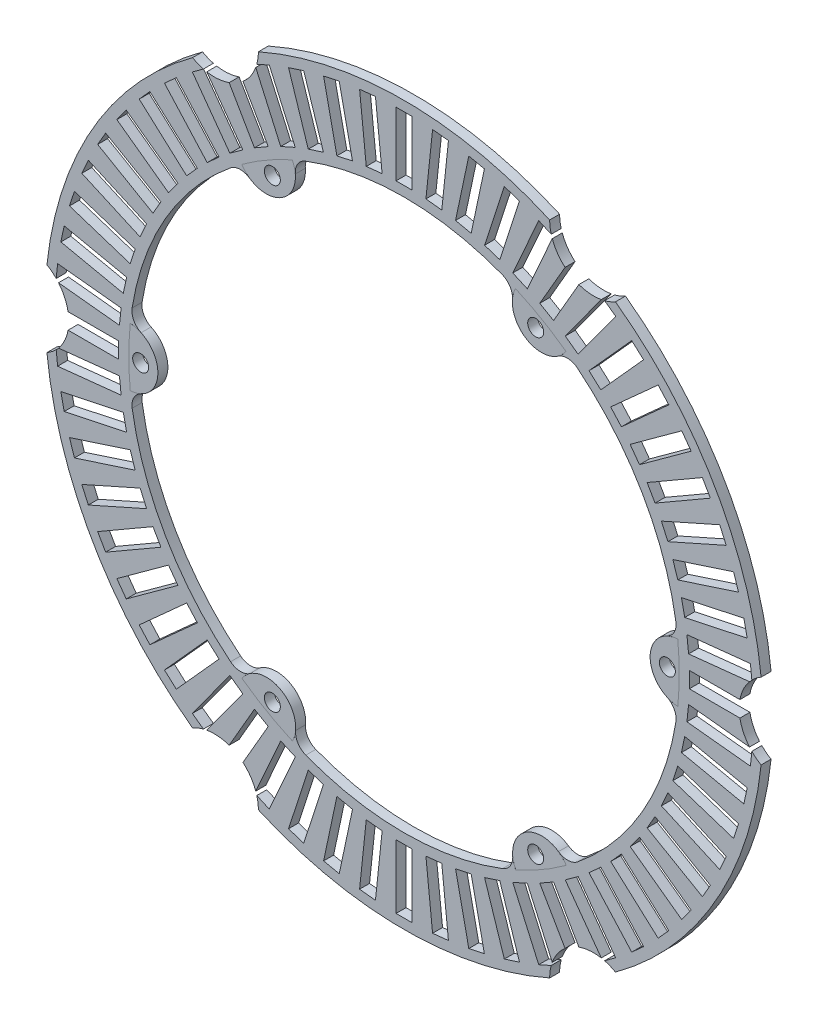
from build123d import *

# Parameters (mm, degrees)
SKETCH1_R                 = 57.15
SKETCH1_R_2               = 43.815
BOSS_EXTRUDE1_DEPTH       = 1.5875
SKETCH4_W                 = 2.54
SKETCH4_H                 = 10.16
CUT_EXTRUDE3_DEPTH        = 5.08
CIRPATTERN2_COUNT         = 60
SKETCH7_R                 = 6.985
CUT_EXTRUDE5_DEPTH        = 2.54
CIRPATTERN4_COUNT         = 6
BOSS_EXTRUDE2_START       = -1.5875
BOSS_EXTRUDE2_DEPTH       = 1.587512
FILLET1_R                 = 2.54
CUT_EXTRUDE6_START        = -2.5875121
SKETCH9_R                 = 1.27
CUT_EXTRUDE6_DEPTH        = 3.5875122
CIRPATTERN12_COUNT        = 6
FILLET1_OF_CIRPATTERN12_R = 2.54


with BuildPart() as part:
    # Sketch1 → Boss-Extrude1 (new body)
    with BuildSketch(Plane.XY):
        Circle(SKETCH1_R)
        Circle(SKETCH1_R_2, mode=Mode.SUBTRACT)
    extrude(amount=BOSS_EXTRUDE1_DEPTH)

    # Sketch4 → Cut-Extrude3 (cut)
    with BuildSketch(Plane.XY.offset(1.5875)):
        with Locations((0, 50.4825)):
            Rectangle(SKETCH4_W, SKETCH4_H)
    cut_extrude3 = extrude(amount=-CUT_EXTRUDE3_DEPTH, mode=Mode.SUBTRACT)

    # CirPattern2: Cut-Extrude3 ×60 about axis
    cirpattern2_axis = Axis((0, 0, 0), (0, 0, 1))
    for i in range(1, CIRPATTERN2_COUNT):
        add(cut_extrude3.rotate(cirpattern2_axis, i * 360 / CIRPATTERN2_COUNT), mode=Mode.SUBTRACT)

    # Sketch7 → Cut-Extrude5 (cut)
    with BuildSketch(Plane(origin=(0, 0, 0), x_dir=(-1, 0, 0), z_dir=(0, 0, -1))):
        with Locations((60.325, 0)):
            Circle(SKETCH7_R)
    cut_extrude5 = extrude(amount=-CUT_EXTRUDE5_DEPTH, mode=Mode.SUBTRACT)

    # CirPattern4: Cut-Extrude5 ×6 about axis
    cirpattern4_axis = Axis((0, 0, 0), (0, 0, 1))
    for i in range(1, CIRPATTERN4_COUNT):
        add(cut_extrude5.rotate(cirpattern4_axis, i * 360 / CIRPATTERN4_COUNT), mode=Mode.SUBTRACT)

    # Sketch8 → Boss-Extrude2 (add)
    with BuildSketch(Plane.XY.offset(1.5875).offset(BOSS_EXTRUDE2_START)):
        with BuildLine():
            ThreePointArc((43.565999419, 4.664538527), (39.168259976, 0.021884291), (43.571184606, -4.615852793))
            ThreePointArc((43.571184606, -4.615852793), (43.814993161, 0.024480537), (43.565999419, 4.664538527))
        make_face()
    boss_extrude2 = extrude(amount=BOSS_EXTRUDE2_DEPTH)

    # Fillet1
    fillet1_edges = [part.edges().sort_by_distance(p)[0] for p in [
        (43.565999419, 4.664538527, 0.79375),
        (43.571184606, -4.615852793, 0.79375),
    ]]
    fillet(fillet1_edges, radius=FILLET1_R)

    # Sketch9 → Cut-Extrude6 (cut)
    with BuildSketch(Plane.XY.offset(1.587512).offset(CUT_EXTRUDE6_START)):
        with Locations((41.91, 0)):
            Circle(SKETCH9_R)
    cut_extrude6 = extrude(amount=CUT_EXTRUDE6_DEPTH, mode=Mode.SUBTRACT)

    # CirPattern12: Boss-Extrude2, Cut-Extrude6 ×6 about axis
    cirpattern12_axis = Axis((0, 0, 0), (0, 0, 1))
    for i in range(1, CIRPATTERN12_COUNT):
        add(boss_extrude2.rotate(cirpattern12_axis, i * 360 / CIRPATTERN12_COUNT))
        add(cut_extrude6.rotate(cirpattern12_axis, i * 360 / CIRPATTERN12_COUNT), mode=Mode.SUBTRACT)

    # Fillet1 of CirPattern12
    fillet1_of_cirpattern12_edges = [part.edges().sort_by_distance(p)[0] for p in [
        (17.743390848, 40.061531501, 0.79375),
        (25.783038082, 35.425826345, 0.79375),
        (-25.82260857, 35.396992974, 0.79375),
        (-17.788146524, 40.041679139, 0.79375),
        (-43.565999419, -4.664538527, 0.79375),
        (-43.571184606, 4.615852793, 0.79375),
        (-17.743390848, -40.061531501, 0.79375),
        (-25.783038082, -35.425826345, 0.79375),
        (25.82260857, -35.396992974, 0.79375),
        (17.788146524, -40.041679139, 0.79375),
    ]]
    fillet(fillet1_of_cirpattern12_edges, radius=FILLET1_OF_CIRPATTERN12_R)


solid = part.part
